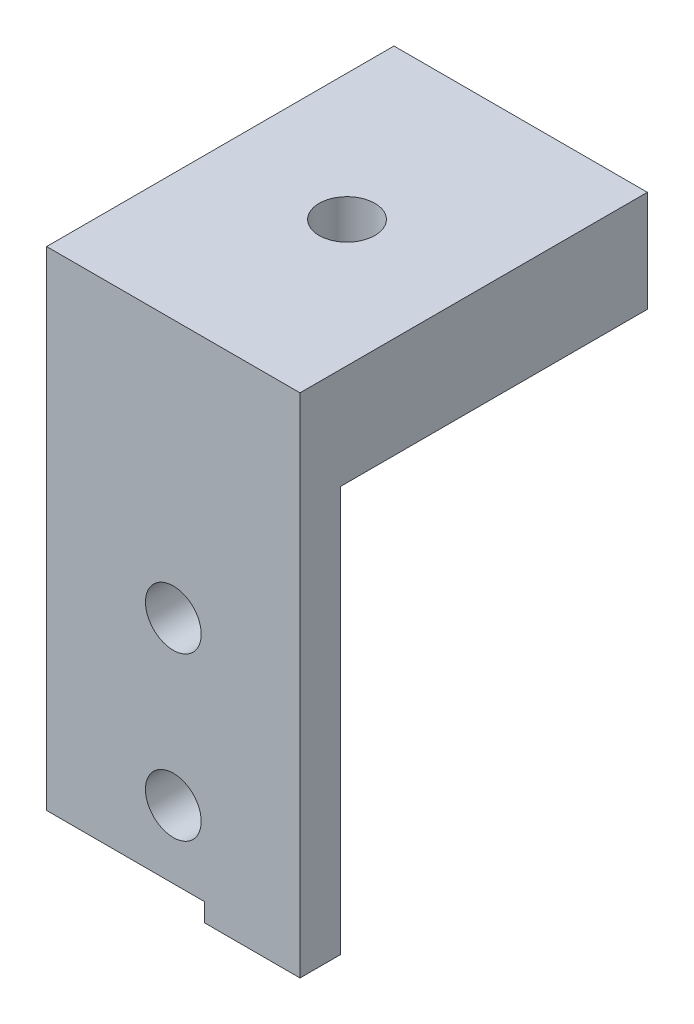
from build123d import *

# Parameters (mm, degrees)
SKETCH1_W                  = 12.5
SKETCH1_H                  = 17.135
TABBASE_DEPTH              = 5
SKETCH2_R                  = 1.375
CHASSISMOUNTINGHOLE_DEPTH  = 5
SKETCH3_W                  = 12.5
SKETCH3_H                  = 26
FRONTTAB_DEPTH             = 5
FRONTMOUNTINGHOLESSKETCH_R = 1.375
FRONTMOUNTINGHOLES_DEPTH   = 5
SKETCH4_W                  = 12.5
SKETCH4_H                  = 21
SKETCH4_R                  = 1.375
CUT_EXTRUDE1_DEPTH         = 3
SKETCH6_W                  = 7.78949329
SKETCH6_H                  = 1.90597399
CUT_EXTRUDE2_DEPTH         = 10
SKETCH7_W                  = 4.71050671
SKETCH7_H                  = 1
CUT_EXTRUDE3_DEPTH         = 10
SKETCH8_W                  = 19.600495403
SKETCH8_H                  = 30.407334014
CUT_EXTRUDE4_DEPTH         = 1
CUT_EXTRUDE4_DEPTH_BACK    = 18.135


with BuildPart() as part:
    # Sketch1 → tabBase (new body)
    with BuildSketch(Plane(origin=(0, 0, 0), x_dir=(1, 0, 0), z_dir=(0, 1, 0))):
        with Locations((6.25, 8.5675)):
            Rectangle(SKETCH1_W, SKETCH1_H)
    extrude(amount=TABBASE_DEPTH)

    # Sketch2 → chassisMountingHole (cut)
    with BuildSketch(Plane(origin=(0, 5, 0), x_dir=(1, 0, 0), z_dir=(0, 1, 0))):
        with Locations((6.25, 8.5675)):
            Circle(SKETCH2_R)
    extrude(amount=-CHASSISMOUNTINGHOLE_DEPTH, mode=Mode.SUBTRACT)

    # Sketch3 → frontTab (add)
    with BuildSketch(Plane.XY):
        with Locations((6.25, -8)):
            Rectangle(SKETCH3_W, SKETCH3_H)
    extrude(amount=-FRONTTAB_DEPTH)

    # frontMountingHolesSketch → frontMountingHoles (cut)
    with BuildSketch(Plane(origin=(0, 0, -5), x_dir=(-1, 0, 0), z_dir=(0, 0, -1))):
        with Locations((-6.25, -15.75)):
            Circle(FRONTMOUNTINGHOLESSKETCH_R)
        with Locations((-6.25, -7.75)):
            Circle(FRONTMOUNTINGHOLESSKETCH_R)
    extrude(amount=-FRONTMOUNTINGHOLES_DEPTH, mode=Mode.SUBTRACT)

    # Sketch4 → Cut-Extrude1 (cut)
    with BuildSketch(Plane(origin=(0, 0, -5), x_dir=(-1, 0, 0), z_dir=(0, 0, -1))):
        with Locations((-6.25, -10.5)):
            Rectangle(SKETCH4_W, SKETCH4_H)
        with Locations((-6.25, -15.75)):
            Circle(SKETCH4_R, mode=Mode.SUBTRACT)
        with Locations((-6.25, -7.75)):
            Circle(SKETCH4_R, mode=Mode.SUBTRACT)
    extrude(amount=-CUT_EXTRUDE1_DEPTH, mode=Mode.SUBTRACT)

    # Sketch6 → Cut-Extrude2 (cut)
    with BuildSketch(Plane(origin=(0, 0, -2), x_dir=(-1, 0, 0), z_dir=(0, 0, -1))):
        with Locations((-8.605253355, -20.047013005)):
            Rectangle(SKETCH6_W, SKETCH6_H)
    extrude(amount=-CUT_EXTRUDE2_DEPTH, mode=Mode.SUBTRACT)

    # Sketch7 → Cut-Extrude3 (cut)
    with BuildSketch(Plane(origin=(0, 0, -2), x_dir=(-1, 0, 0), z_dir=(0, 0, -1))):
        with Locations((-2.355253355, -20.5)):
            Rectangle(SKETCH7_W, SKETCH7_H)
    extrude(amount=-CUT_EXTRUDE3_DEPTH, mode=Mode.SUBTRACT)

    # Mirror1: part across plane


with BuildPart() as part_1:
    add(part.part)
    add(part.part.mirror(Plane(origin=(0, 5, 0), x_dir=(0, 0, 1), z_dir=(1, 0, 0))))

    # Sketch8 → Cut-Extrude4 (cut, two sides)
    with BuildSketch(Plane(origin=(0, 0, -17.135), x_dir=(-1, 0, 0), z_dir=(0, 0, -1))) as cut_extrude4_sk:
        with Locations((-9.800247702, -10.203667007)):
            Rectangle(SKETCH8_W, SKETCH8_H)
    extrude(amount=CUT_EXTRUDE4_DEPTH, mode=Mode.SUBTRACT)
    extrude(cut_extrude4_sk.sketch, amount=-CUT_EXTRUDE4_DEPTH_BACK, mode=Mode.SUBTRACT)


solid = part_1.part
